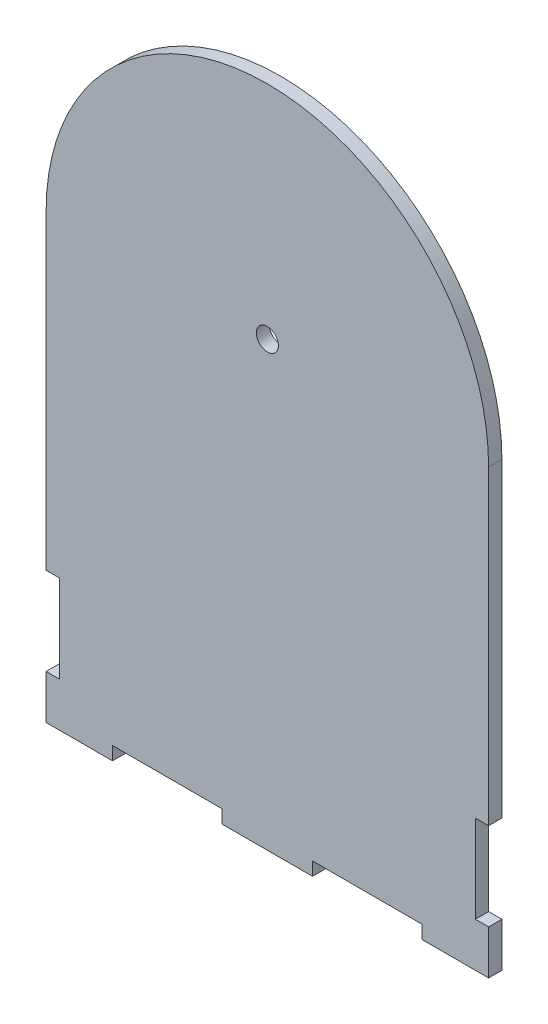
from build123d import *

# Parameters (mm, degrees)
SKETCH1_R           = 2.5
BOSS_EXTRUDE1_DEPTH = 3


with BuildPart() as part:
    # Sketch1 → Boss-Extrude1 (new body)
    with BuildSketch(Plane.XY):
        with BuildLine():
            Line((0, 10), (0, 0))
            Line((0, 0), (15, 0))
            Line((15, 0), (15, 3))
            Line((15, 3), (39.8, 3))
            Line((39.8, 3), (39.8, 0))
            Line((39.8, 0), (60.2, 0))
            Line((60.2, 0), (60.2, 3))
            Line((60.2, 3), (85, 3))
            Line((85, 3), (85, 0))
            Line((85, 0), (100, 0))
            Line((100, 0), (100, 10))
            Line((100, 10), (97, 10))
            Line((97, 10), (97, 29.8))
            Line((97, 29.8), (100, 29.8))
            Line((100, 29.8), (100, 100))
            ThreePointArc((100, 100), (50, 150), (0, 100))
            Line((0, 100), (0, 29.8))
            Line((0, 29.8), (3, 29.8))
            Line((3, 29.8), (3, 10))
            Line((3, 10), (0, 10))
        make_face()
        with Locations((50, 100)):
            Circle(SKETCH1_R, mode=Mode.SUBTRACT)
    extrude(amount=BOSS_EXTRUDE1_DEPTH)


solid = part.part
